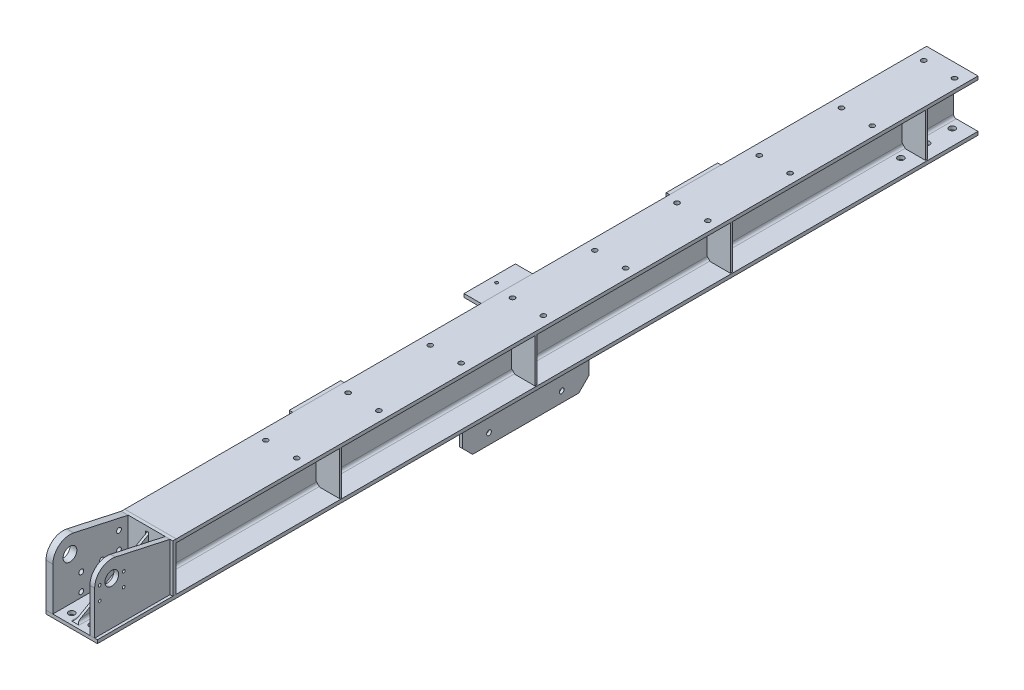
from build123d import *

# Parameters (mm, degrees)
H_HW150_1_DEPTH              = 2570
CUT_EXTRUDE_1_DEPTH          = 150
EXTRUDE_1_DEPTH              = 10
SKETCH_15_R                  = 9
CUT_EXTRUDE_2_DEPTH          = 10
EXTRUDE_2_DEPTH              = 14
EXTRUDE_3_DEPTH              = 20
CUT_EXTRUDE_START            = -142
SKETCH_19_R                  = 20
CUT_EXTRUDE_3_DEPTH          = 142
SKETCH_21_R                  = 7
CUT_EXTRUDE_4_DEPTH          = 20
SKETCH_22_R                  = 4
CUT_EXTRUDE_5_DEPTH          = 14
SKETCH_23_W                  = 8
SKETCH_23_H                  = 370
EXTRUDE_5_DEPTH              = 140
CHAMFER_1_SIZE               = 30
SKETCH_24_R                  = 7
CUT_EXTRUDE_6_DEPTH          = 8
SKETCH_26_W                  = 10
SKETCH_26_H                  = 130
EXTRUDE_7_DEPTH              = 148
SKETCH_27_R                  = 7
SKETCH_27_R_2                = 6.961767408
CUT_EXTRUDE_7_DEPTH          = 10
SKETCH_28_R                  = 7
CUT_EXTRUDE_8_DEPTH          = 10
EXTRUDE_8_DEPTH              = 6
PATTERN_LINEAR_1_COUNT       = 4
PATTERN_LINEAR_1_PITCH       = 570
SKETCH_30_W                  = 150
SKETCH_30_H                  = 150
EXTRUDE_9_DEPTH              = 10
PATTERN_LINEAR_2_COUNT       = 3
PATTERN_LINEAR_2_PITCH       = 550
SKETCH_32_W                  = 150
SKETCH_32_H                  = 10
EXTRUDE_10_DEPTH             = 40
FILLET_1_R                   = 4
SKETCH_33_W                  = 150
SKETCH_33_H                  = 10
EXTRUDE_11_DEPTH             = 40
FILLET_2_R                   = 4
SKETCH_34_W                  = 150
SKETCH_34_H                  = 10
EXTRUDE_12_DEPTH             = 40
FILLET_3_R                   = 4
SKETCH_36_W                  = 4.25
SKETCH_36_H                  = 10.001
SKETCH_37_W                  = 4.25
SKETCH_37_H                  = 10.001
HOLE_WIZARD_M10_2_AT_2_COUNT = 2
HOLE_WIZARD_M10_2_AT_2_PITCH = 1100


with BuildPart() as part:
    # 草图12 → H型钢 HW150(1) (new body)
    with BuildSketch(Plane(origin=(75, -1020.059944647, 4785.417313278), x_dir=(1, 0, 0), z_dir=(0, 0, 1))):
        with BuildLine():
            Line((-75, -75), (75, -75))
            Line((75, -75), (75, -65))
            Line((75, -65), (11.5, -65))
            ThreePointArc((11.5, -65), (5.843145751, -62.656854249), (3.5, -57))
            Line((3.5, -57), (3.5, 57))
            ThreePointArc((3.5, 57), (5.843145751, 62.656854249), (11.5, 65))
            Line((11.5, 65), (75, 65))
            Line((75, 65), (75, 75))
            Line((75, 75), (-75, 75))
            Line((-75, 75), (-75, 65))
            Line((-75, 65), (-11.5, 65))
            ThreePointArc((-11.5, 65), (-5.843145751, 62.656854249), (-3.5, 57))
            Line((-3.5, 57), (-3.5, -57))
            ThreePointArc((-3.5, -57), (-5.843145751, -62.656854249), (-11.5, -65))
            Line((-11.5, -65), (-75, -65))
            Line((-75, -65), (-75, -75))
        make_face()
    extrude(amount=H_HW150_1_DEPTH)

    # 草图13 → 切除-拉伸1 (cut)
    with BuildSketch(Plane(origin=(150, 0, 0), x_dir=(0, 0, -1), z_dir=(1, 0, 0))):
        Polygon((-7355.417313278, -945.059944647), (-7125.417313278, -945.059944647), (-7125.417313278, -960.059944647), (-7345.417313278, -1085.059944647), (-7355.417313278, -1085.059944647), align=None)
    extrude(amount=-CUT_EXTRUDE_1_DEPTH, mode=Mode.SUBTRACT)

    # 草图15 → 切除-拉伸2 (cut)
    with BuildSketch(Plane.XZ.offset(1095.059944647)):
        with Locations(Location((105, 7325.417313278, 0), (0, 0, 270))):
            Circle(SKETCH_15_R)
        with Locations(Location((45, 7325.417313278, 0), (0, 0, 270))):
            Circle(SKETCH_15_R)
        with Locations(Location((45, 7250.417313278, 0), (0, 0, 270))):
            Circle(SKETCH_15_R)
        with Locations(Location((105, 7250.417313278, 0), (0, 0, 270))):
            Circle(SKETCH_15_R)
        with Locations(Location((105, 7175.417313278, 0), (0, 0, 270))):
            Circle(SKETCH_15_R)
        with Locations(Location((45, 7175.417313278, 0), (0, 0, 270))):
            Circle(SKETCH_15_R)
        with Locations(Location((105, 4965.417313278, 0), (0, 0, 270))):
            Circle(SKETCH_15_R)
        with Locations(Location((45, 4965.417313278, 0), (0, 0, 270))):
            Circle(SKETCH_15_R)
        with Locations(Location((105, 4890.417313278, 0), (0, 0, 270))):
            Circle(SKETCH_15_R)
        with Locations(Location((45, 4890.417313278, 0), (0, 0, 270))):
            Circle(SKETCH_15_R)
        with Locations(Location((45, 4815.417313278, 0), (0, 0, 270))):
            Circle(SKETCH_15_R)
        with Locations(Location((105, 4815.417313278, 0), (0, 0, 270))):
            Circle(SKETCH_15_R)
    extrude(amount=-CUT_EXTRUDE_2_DEPTH, mode=Mode.SUBTRACT)

    # 草图28 → 切除-拉伸8 (cut)
    with BuildSketch(Plane(origin=(0, -945.059944647, 0), x_dir=(1, 0, 0), z_dir=(0, 1, 0))):
        with Locations(Location((121.5, -6745.417313278, 0), (0, 0, 270))):
            Circle(SKETCH_28_R)
        with Locations(Location((31.5, -6745.417313278, 0), (0, 0, 270))):
            Circle(SKETCH_28_R)
        with Locations(Location((121.5, -6505.417313278, 0), (0, 0, 270))):
            Circle(SKETCH_28_R)
        with Locations(Location((31.5, -6505.417313278, 0), (0, 0, 270))):
            Circle(SKETCH_28_R)
        with Locations(Location((121.5, -6265.417313278, 0), (0, 0, 270))):
            Circle(SKETCH_28_R)
        with Locations(Location((31.5, -6265.417313278, 0), (0, 0, 270))):
            Circle(SKETCH_28_R)
        with Locations(Location((121.5, -6025.417313278, 0), (0, 0, 270))):
            Circle(SKETCH_28_R)
        with Locations(Location((31.5, -6025.417313278, 0), (0, 0, 270))):
            Circle(SKETCH_28_R)
        with Locations(Location((121.5, -5785.417313278, 0), (0, 0, 270))):
            Circle(SKETCH_28_R)
        with Locations(Location((31.5, -5785.417313278, 0), (0, 0, 270))):
            Circle(SKETCH_28_R)
        with Locations(Location((121.5, -5545.417313278, 0), (0, 0, 270))):
            Circle(SKETCH_28_R)
        with Locations(Location((31.5, -5545.417313278, 0), (0, 0, 270))):
            Circle(SKETCH_28_R)
        with Locations(Location((121.5, -5305.417313278, 0), (0, 0, 270))):
            Circle(SKETCH_28_R)
        with Locations(Location((31.5, -5305.417313278, 0), (0, 0, 270))):
            Circle(SKETCH_28_R)
        with Locations(Location((121.5, -5065.417313278, 0), (0, 0, 270))):
            Circle(SKETCH_28_R)
        with Locations(Location((31.5, -5065.417313278, 0), (0, 0, 270))):
            Circle(SKETCH_28_R)
        with Locations(Location((121.5, -4825.417313278, 0), (0, 0, 270))):
            Circle(SKETCH_28_R)
        with Locations(Location((31.5, -4825.417313278, 0), (0, 0, 270))):
            Circle(SKETCH_28_R)
    extrude(amount=-CUT_EXTRUDE_8_DEPTH, mode=Mode.SUBTRACT)


with BuildPart() as body_2:
    # 草图14 → 凸台-拉伸1 (new body)
    with BuildSketch(Plane.XY.offset(7125.417313278)):
        Polygon((0, -945.059944647), (150, -945.059944647), (150, -1085.059944647), (87.914213562, -1085.059944647), (79, -1076.145731085), (79, -959.059944647), (71, -959.059944647), (71, -1076.145731085), (62.085786438, -1085.059944647), (0, -1085.059944647), align=None)
    extrude(amount=EXTRUDE_1_DEPTH)


with BuildPart() as body_3:
    # 草图17 → 凸台-拉伸2 (new body)
    with BuildSketch(Plane(origin=(142, 0, 0), x_dir=(0, 0, -1), z_dir=(1, 0, 0))):
        with BuildLine():
            Line((-7135.417313278, -945.059944647), (-7135.417313278, -1085.059944647))
            Line((-7135.417313278, -1085.059944647), (-7355.417313278, -1085.059944647))
            Line((-7355.417313278, -1085.059944647), (-7355.417313278, -959.059944647))
            ThreePointArc((-7355.417313278, -959.059944647), (-7336.768818219, -920.110193198), (-7294.73398776, -910.214611647))
            Line((-7294.73398776, -910.214611647), (-7135.417313278, -945.059944647))
        make_face()
    extrude(amount=-EXTRUDE_2_DEPTH)


with BuildPart() as body_4:
    # 草图18 → 凸台-拉伸3 (new body)
    with BuildSketch(Plane.ZY):
        with BuildLine():
            Line((7294.73398776, -910.214611647), (7135.417313278, -945.059944647))
            Line((7135.417313278, -945.059944647), (7135.417313278, -1085.059944647))
            Line((7135.417313278, -1085.059944647), (7355.417313278, -1085.059944647))
            Line((7355.417313278, -1085.059944647), (7355.417313278, -959.059944647))
            ThreePointArc((7355.417313278, -959.059944647), (7336.768818219, -920.110193198), (7294.73398776, -910.214611647))
        make_face()
    extrude(amount=-EXTRUDE_3_DEPTH)


with BuildPart() as cut_extrude_3_tool:
    # 草图19 → 切除-拉伸3 (new body)
    with BuildSketch(Plane(origin=(142, 0, 0), x_dir=(0, 0, -1), z_dir=(1, 0, 0)).offset(CUT_EXTRUDE_START)):
        with Locations(Location((-7305.417313278, -958.559944647, 0), (0, 0, 180))):
            Circle(SKETCH_19_R)
    extrude(amount=CUT_EXTRUDE_3_DEPTH)


with BuildPart() as body_3_1:
    add(body_3.part)

    # 切除-拉伸3: cut by cut_extrude_3_tool
    add(cut_extrude_3_tool.part, mode=Mode.SUBTRACT)

    # 草图22 → 切除-拉伸5 (cut)
    with BuildSketch(Plane(origin=(142, 0, 0), x_dir=(0, 0, -1), z_dir=(1, 0, 0))):
        with Locations((-7340.417313278, -958.559944647)):
            Circle(SKETCH_22_R)
        with Locations((-7270.417313278, -958.559944647)):
            Circle(SKETCH_22_R)
        with Locations((-7340.417313278, -998.559944647)):
            Circle(SKETCH_22_R)
        with Locations((-7270.417313278, -998.559944647)):
            Circle(SKETCH_22_R)
    extrude(amount=-CUT_EXTRUDE_5_DEPTH, mode=Mode.SUBTRACT)


with BuildPart() as body_4_1:
    add(body_4.part)

    # 切除-拉伸3: cut by cut_extrude_3_tool
    add(cut_extrude_3_tool.part, mode=Mode.SUBTRACT)

    # 草图21 → 切除-拉伸4 (cut)
    with BuildSketch(Plane.ZY):
        with Locations(Location((7162.417313278, -1070.059944647, 0), (0, 0, 270))):
            Circle(SKETCH_21_R)
        with Locations(Location((7162.417313278, -1020.059944647, 0), (0, 0, 270))):
            Circle(SKETCH_21_R)
        with Locations(Location((7212.417313278, -1070.059944647, 0), (0, 0, 270))):
            Circle(SKETCH_21_R)
        with Locations(Location((7212.417313278, -1020.059944647, 0), (0, 0, 270))):
            Circle(SKETCH_21_R)
        with Locations(Location((7162.417313278, -970.059944647, 0), (0, 0, 270))):
            Circle(SKETCH_21_R)
        with Locations(Location((7272.417313278, -1020.059944647, 0), (0, 0, 270))):
            Circle(SKETCH_21_R)
        with Locations(Location((7272.417313278, -1070.059944647, 0), (0, 0, 270))):
            Circle(SKETCH_21_R)
    extrude(amount=-CUT_EXTRUDE_4_DEPTH, mode=Mode.SUBTRACT)


with BuildPart() as body_5:
    # 草图23 → 凸台-拉伸5 (new body)
    with BuildSketch(Plane.XZ.offset(1095.059944647)):
        with Locations((75, 6034.417313278)):
            Rectangle(SKETCH_23_W, SKETCH_23_H)
    extrude(amount=EXTRUDE_5_DEPTH)

    # 倒角1
    chamfer_1_edges = [body_5.edges().sort_by_distance(p)[0] for p in [
        (75, -1235.059944647, 6219.417313278),
        (75, -1235.059944647, 5849.417313278),
    ]]
    chamfer(chamfer_1_edges, length=CHAMFER_1_SIZE)

    # 草图24 → 切除-拉伸6 (cut)
    with BuildSketch(Plane(origin=(79, 0, 0), x_dir=(0, 0, -1), z_dir=(1, 0, 0))):
        with Locations((-6101.417313278, -1135.059944647)):
            Circle(SKETCH_24_R)
        with Locations((-5969.417313278, -1135.059944647)):
            Circle(SKETCH_24_R)
        with Locations((-6141.417313278, -1204.34197695)):
            Circle(SKETCH_24_R)
        with Locations((-5929.417313278, -1204.34197695)):
            Circle(SKETCH_24_R)
    extrude(amount=-CUT_EXTRUDE_6_DEPTH, mode=Mode.SUBTRACT)


with BuildPart() as body_6:
    # 草图26 → 凸台-拉伸7 (new body)
    with BuildSketch(Plane(origin=(0, 0, 4785.417313278), x_dir=(-1, 0, 0), z_dir=(0, 0, -1))):
        with Locations((-5, -1020.059944647)):
            Rectangle(SKETCH_26_W, SKETCH_26_H)
    extrude(amount=-EXTRUDE_7_DEPTH)

    # 草图27 → 切除-拉伸7 (cut)
    with BuildSketch(Plane.ZY):
        with Locations(Location((4810.417313278, -970.059944647, 0), (0, 0, 270))):
            Circle(SKETCH_27_R)
        with Locations(Location((4908.417313278, -970.059944647, 0), (0, 0, 270))):
            Circle(SKETCH_27_R)
        with Locations(Location((4810.417313278, -1070.059944647, 0), (0, 0, 270))):
            Circle(SKETCH_27_R)
        with Locations(Location((4908.417313278, -1070.059944647, 0), (0, 0, 270))):
            Circle(SKETCH_27_R)
        with Locations(Location((4908.417313278, -1020.059944647, 0), (0, 0, 270))):
            Circle(SKETCH_27_R)
        with Locations(Location((4810.417313278, -1020.059944647, 0), (0, 0, 270))):
            Circle(SKETCH_27_R_2)
    extrude(amount=-CUT_EXTRUDE_7_DEPTH, mode=Mode.SUBTRACT)


with BuildPart() as body_7:
    # 草图29 → 凸台-拉伸8 (new body)
    with BuildSketch(Plane(origin=(0, 0, 4935.417313278), x_dir=(-1, 0, 0), z_dir=(0, 0, -1))):
        Polygon((-147, -955.059944647), (-88.5, -955.059944647), (-78.5, -965.059944647), (-78.5, -1075.059944647), (-88.5, -1085.059944647), (-147, -1085.059944647), align=None)
    extrude_8 = extrude(amount=EXTRUDE_8_DEPTH)


with BuildPart() as pattern_linear_1_1:
    # 阵列(线性)1: 凸台-拉伸8 ×4
    with Locations(*[(0, 0, i * PATTERN_LINEAR_1_PITCH) for i in range(1, PATTERN_LINEAR_1_COUNT)]):
        add(extrude_8)


with BuildPart() as body_11:
    # 草图30 → 凸台-拉伸9 (new body)
    with BuildSketch(Plane.ZY):
        with Locations((5460.417313278, -1020.059944647)):
            Rectangle(SKETCH_30_W, SKETCH_30_H)
        with BuildLine():
            Line((5420.417313278, -970.059944647), (5420.417313278, -1070.059944647))
            ThreePointArc((5420.417313278, -1070.059944647), (5425.417313278, -1075.059944647), (5430.417313278, -1070.059944647))
            Line((5430.417313278, -1070.059944647), (5430.417313278, -970.059944647))
            ThreePointArc((5430.417313278, -970.059944647), (5425.417313278, -965.059944647), (5420.417313278, -970.059944647))
        make_face(mode=Mode.SUBTRACT)
        with BuildLine():
            Line((5490.417313278, -970.059944647), (5490.417313278, -1070.059944647))
            ThreePointArc((5490.417313278, -1070.059944647), (5495.417313278, -1075.059944647), (5500.417313278, -1070.059944647))
            Line((5500.417313278, -1070.059944647), (5500.417313278, -970.059944647))
            ThreePointArc((5500.417313278, -970.059944647), (5495.417313278, -965.059944647), (5490.417313278, -970.059944647))
        make_face(mode=Mode.SUBTRACT)
    extrude_9 = extrude(amount=EXTRUDE_9_DEPTH)

    # 草图32 → 凸台-拉伸10 (add)
    with BuildSketch(Plane.ZY.offset(10)):
        with Locations((5460.417313278, -1090.059944647)):
            Rectangle(SKETCH_32_W, SKETCH_32_H)
    extrude(amount=EXTRUDE_10_DEPTH)

    # 圆角1
    fillet_1_edges = [body_11.edges().sort_by_distance(p)[0] for p in [
        (-10, -1085.059944647, 5460.417313278),
    ]]
    fillet(fillet_1_edges, radius=FILLET_1_R)

    # 草图37 → M10 螺纹孔2 (revolve, cut)
    with BuildSketch(Plane(origin=(-30, -1095.059944647, 5460.417313278), x_dir=(0, 0, -1), z_dir=(1, 0, 0))):
        with Locations((2.125, 5.0005)):
            Rectangle(SKETCH_37_W, SKETCH_37_H)
    hole_wizard_m10_2 = revolve(axis=Axis((-30, -1101.409944647, 5460.417313278), (0, 1, 0)), mode=Mode.SUBTRACT)


with BuildPart() as pattern_linear_2_1:
    # 阵列(线性)2: pattern copy
    add(extrude_9.moved(Location(Vector(0, 0, 1) * (1 * PATTERN_LINEAR_2_PITCH))))

    # 草图33 → 凸台-拉伸11 (add)
    with BuildSketch(Plane.ZY.offset(10)):
        with Locations((6010.417313278, -950.059944647)):
            Rectangle(SKETCH_33_W, SKETCH_33_H)
    extrude(amount=EXTRUDE_11_DEPTH)

    # 圆角2
    fillet_2_edges = [pattern_linear_2_1.edges().sort_by_distance(p)[0] for p in [
        (-10, -955.059944647, 6010.417313278),
    ]]
    fillet(fillet_2_edges, radius=FILLET_2_R)

    # 草图36 → M10 螺纹孔1 (revolve, cut)
    with BuildSketch(Plane(origin=(-30, -945.059944647, 6010.417313278), x_dir=(0, 0, 1), z_dir=(1, 0, 0))):
        with Locations((2.125, 5.0005)):
            Rectangle(SKETCH_36_W, SKETCH_36_H)
    revolve(axis=Axis((-30, -938.709944647, 6010.417313278), (0, -1, 0)), mode=Mode.SUBTRACT)


with BuildPart() as pattern_linear_2_2:
    # 阵列(线性)2: pattern copy
    add(extrude_9.moved(Location(Vector(0, 0, 1) * (2 * PATTERN_LINEAR_2_PITCH))))

    # 草图34 → 凸台-拉伸12 (add)
    with BuildSketch(Plane.ZY.offset(10)):
        with Locations((6560.417313278, -1090.059944647)):
            Rectangle(SKETCH_34_W, SKETCH_34_H)
    extrude(amount=EXTRUDE_12_DEPTH)

    # 圆角3
    fillet_3_edges = [pattern_linear_2_2.edges().sort_by_distance(p)[0] for p in [
        (-10, -1085.059944647, 6560.417313278),
    ]]
    fillet(fillet_3_edges, radius=FILLET_3_R)

    # M10 螺纹孔2 at 2: M10 螺纹孔2 ×2
    with Locations(*[(0, 0, i * HOLE_WIZARD_M10_2_AT_2_PITCH) for i in range(1, HOLE_WIZARD_M10_2_AT_2_COUNT)]):
        add(hole_wizard_m10_2, mode=Mode.SUBTRACT)


solid = Compound([part.part, body_2.part, body_3_1.part, body_4_1.part, body_5.part, body_6.part, body_7.part, pattern_linear_1_1.part, body_11.part, pattern_linear_2_1.part, pattern_linear_2_2.part])
